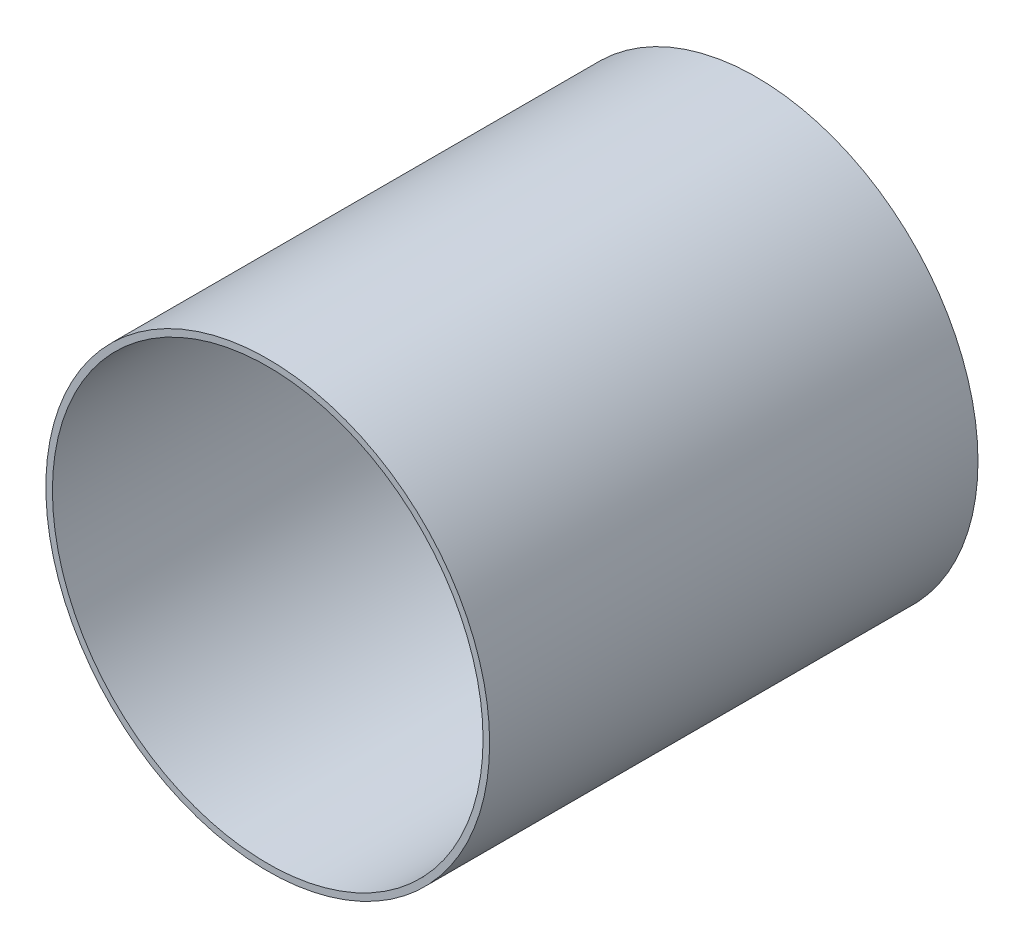
from build123d import *

# Parameters (mm, degrees)
SKETCH1_R           = 63.4746
SKETCH1_R_2         = 61.595
BOSS_EXTRUDE1_DEPTH = 69.85


with BuildPart() as part:
    # Sketch1 → Boss-Extrude1 (new body, symmetric)
    with BuildSketch(Plane.XY):
        Circle(SKETCH1_R)
        Circle(SKETCH1_R_2, mode=Mode.SUBTRACT)
    extrude(amount=BOSS_EXTRUDE1_DEPTH, both=True)


solid = part.part
